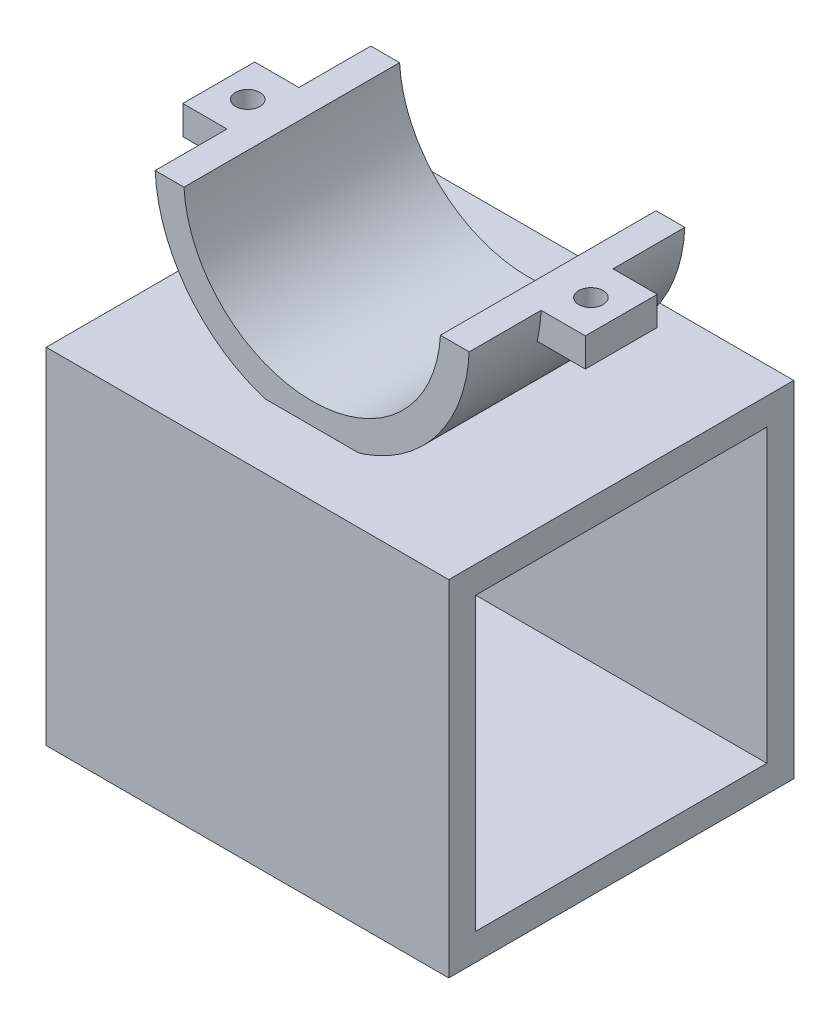
from build123d import *

# Parameters (mm, degrees)
SKETCH1_W                = 4
SKETCH1_H                = 30
REVOLVE1_ANGLE           = 180
SKETCH6_W                = 8.13
SKETCH6_H                = 5
BOSS_EXTRUDE3_DEPTH      = 5
BOSS_EXTRUDE3_DEPTH_BACK = 5
M3_CLEARANCE_HOLE1_D     = 3.4
M3_CLEARANCE_HOLE1_DEPTH = 8.87
M3_CLEARANCE_HOLE1_TIP   = 1.021463052
SKETCH11_W               = 62.08504313
SKETCH11_H               = 41.873291452
CUT_EXTRUDE1_DEPTH       = 1
SKETCH4_W                = 48
SKETCH4_H                = 48
SKETCH4_W_2              = 40.5
SKETCH4_H_2              = 40.5
BOSS_EXTRUDE4_DEPTH      = 28
BOSS_EXTRUDE4_DEPTH_BACK = 28


with BuildPart() as part:
    # Sketch1 → Revolve1 (revolve)
    with BuildSketch(Plane(origin=(0, 0, 0), x_dir=(1, 0, 0), z_dir=(0, 1, 0))):
        with Locations((-19.87, 0)):
            Rectangle(SKETCH1_W, SKETCH1_H)
    revolve(axis=Axis((0, 0, -19.621046531), (0, 0, 1)), revolution_arc=REVOLVE1_ANGLE)

    # Sketch6 → Boss-Extrude3 (add, two sides)
    with BuildSketch(Plane.XY) as boss_extrude3_sk:
        with Locations((-23.935, -2.5)):
            Rectangle(SKETCH6_W, SKETCH6_H)
        with Locations((23.935, -2.5)):
            Rectangle(SKETCH6_W, SKETCH6_H)
    extrude(amount=BOSS_EXTRUDE3_DEPTH)
    extrude(boss_extrude3_sk.sketch, amount=-BOSS_EXTRUDE3_DEPTH_BACK)

    # M3 Clearance Hole1
    with Locations(Plane(origin=(0, 0, 0), x_dir=(1, 0, 0), z_dir=(0, 1, 0))):
        with Locations((-23.970037453, 0), (23.778277154, 0)):
            Hole(M3_CLEARANCE_HOLE1_D / 2, depth=M3_CLEARANCE_HOLE1_DEPTH)
            with Locations((0, 0, -(M3_CLEARANCE_HOLE1_DEPTH + M3_CLEARANCE_HOLE1_TIP / 2))):  # 118° drill point
                Cone(0, M3_CLEARANCE_HOLE1_D / 2, M3_CLEARANCE_HOLE1_TIP, mode=Mode.SUBTRACT)

    # Sketch11 → Cut-Extrude1 (cut)
    with BuildSketch(Plane(origin=(0, 0, 0), x_dir=(1, 0, 0), z_dir=(0, 1, 0))):
        Rectangle(SKETCH11_W, SKETCH11_H)
    extrude(amount=-CUT_EXTRUDE1_DEPTH, mode=Mode.SUBTRACT)


with BuildPart() as body_2:
    # Sketch4 → Boss-Extrude4 (new body, two sides)
    with BuildSketch(Plane(origin=(0, 0, 0), x_dir=(0, 0, -1), z_dir=(1, 0, 0))) as boss_extrude4_sk:
        with Locations((0, -44.87)):
            Rectangle(SKETCH4_W, SKETCH4_H)
        with Locations((0, -44.87)):
            Rectangle(SKETCH4_W_2, SKETCH4_H_2, mode=Mode.SUBTRACT)
    extrude(amount=BOSS_EXTRUDE4_DEPTH)
    extrude(boss_extrude4_sk.sketch, amount=-BOSS_EXTRUDE4_DEPTH_BACK)

    # Sketch10 → M8 Clearance Hole1 (revolve, cut)
    with BuildSketch(Plane(origin=(0, -65.12, 0), x_dir=(0, 0, 1), z_dir=(1, 0, 0))):
        Polygon((0, 0), (0, 11.573872786), (4.5, 8.87), (4.5, 0), align=None)
    revolve(axis=Axis((0, -58.77, 0), (0, -1, 0)), mode=Mode.SUBTRACT)


solid = Compound([part.part, body_2.part])
